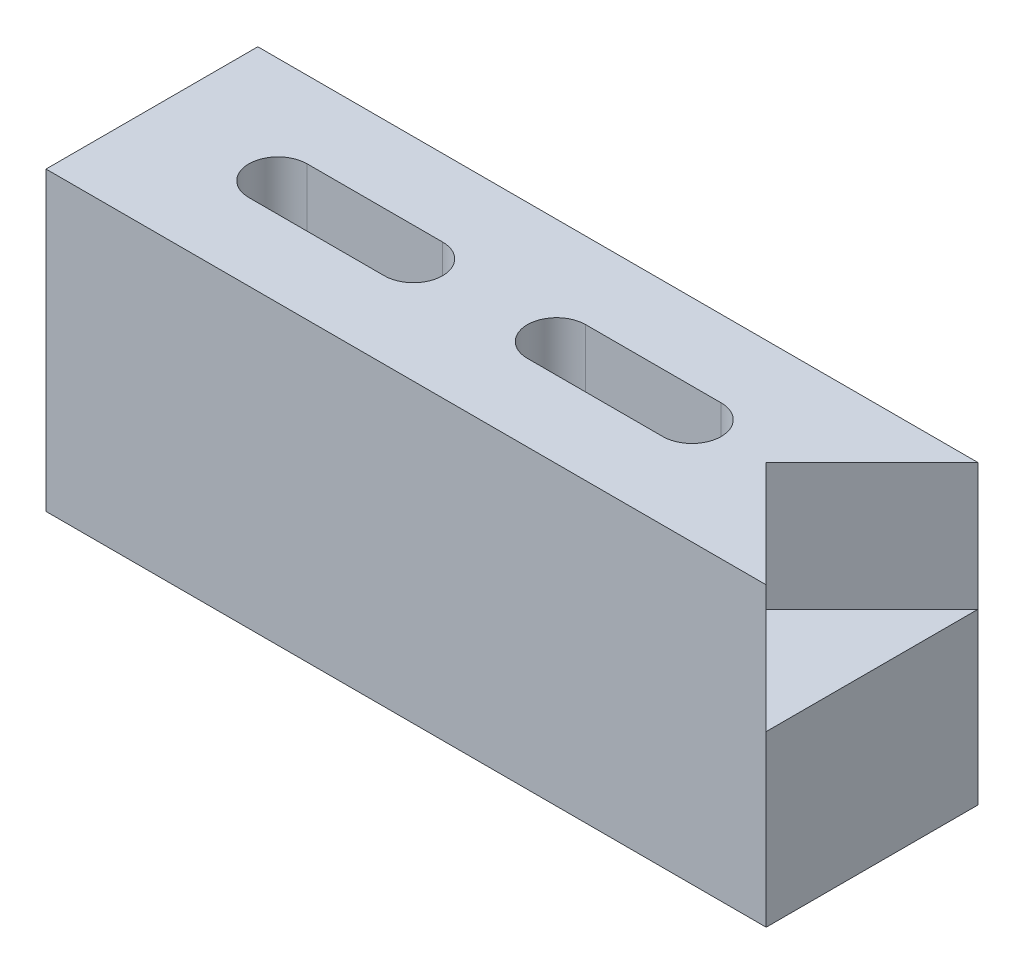
from build123d import *

# Parameters (mm, degrees)
SKETCH1_W           = 43.18
SKETCH1_H           = 17.78
BOSS_EXTRUDE1_DEPTH = 12.7
CUT_EXTRUDE1_DEPTH  = 7.62
CUT_EXTRUDE2_DEPTH  = 18.78


with BuildPart() as part:
    # Sketch1 → Boss-Extrude1 (new body)
    with BuildSketch(Plane.XY):
        with Locations((21.59, 8.89)):
            Rectangle(SKETCH1_W, SKETCH1_H)
    extrude(amount=-BOSS_EXTRUDE1_DEPTH)

    # Sketch3 → Cut-Extrude1 (cut)
    with BuildSketch(Plane(origin=(0, 17.78, 0), x_dir=(1, 0, 0), z_dir=(0, 1, 0))):
        Polygon((43.18, 12.7), (36.83, 6.35), (43.18, 0), align=None)
    extrude(amount=-CUT_EXTRUDE1_DEPTH, mode=Mode.SUBTRACT)

    # Sketch4 → Cut-Extrude2 (cut, through all)
    with BuildSketch(Plane(origin=(0, 17.78, 0), x_dir=(1, 0, 0), z_dir=(0, 1, 0))):
        with BuildLine():
            Line((32.381000008, 4.599999944), (24.260999992, 4.599999944))
            ThreePointArc((24.260999992, 4.599999944), (22.510999936, 6.35), (24.260999992, 8.100000056))
            Line((24.260999992, 8.100000056), (32.381000008, 8.100000056))
            ThreePointArc((32.381000008, 8.100000056), (34.131000064, 6.35), (32.381000008, 4.599999944))
        make_face()
        with BuildLine():
            Line((15.68099988, 4.599999944), (7.560999864, 4.599999944))
            ThreePointArc((7.560999864, 4.599999944), (5.810999808, 6.35), (7.560999864, 8.100000056))
            Line((7.560999864, 8.100000056), (15.68099988, 8.100000056))
            ThreePointArc((15.68099988, 8.100000056), (17.430999936, 6.35), (15.68099988, 4.599999944))
        make_face()
    extrude(amount=-CUT_EXTRUDE2_DEPTH, mode=Mode.SUBTRACT)


solid = part.part
